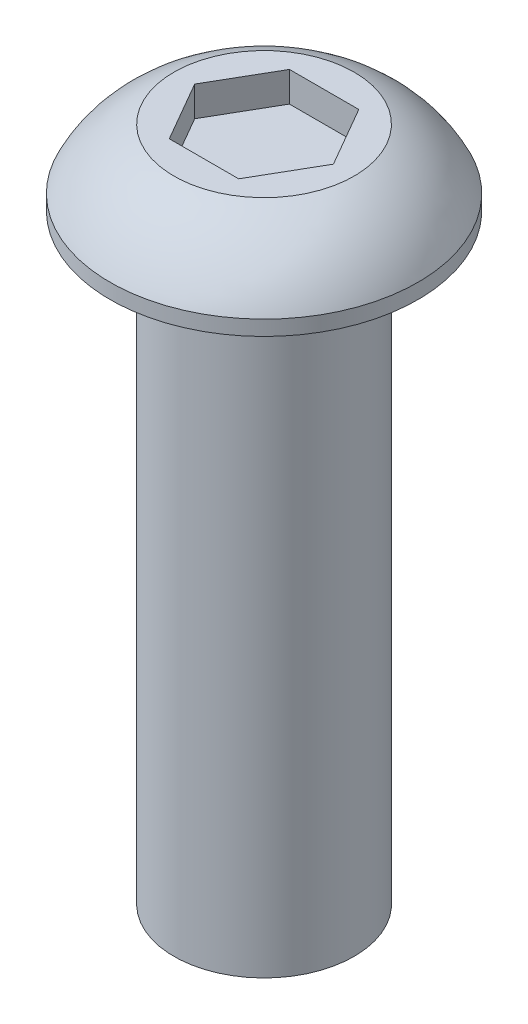
from build123d import *

# Parameters (mm, degrees)
CUT_EXTRUDE1_DEPTH = 1


with BuildPart() as part:
    # Sketch1 → Revolve1 (revolve)
    with BuildSketch(Plane.XY):
        with BuildLine():
            Line((3, 0), (5.125, 0))
            Line((5.125, 0), (5.125, 0.5))
            ThreePointArc((5.125, 0.5), (4.25139218, 1.700697941), (3, 2.5))
            Line((3, 2.5), (0, 2.5))
            Line((0, 2.5), (0, -20))
            Line((0, -20), (3, -20))
            Line((3, -20), (3, 0))
        make_face()
    revolve(axis=Axis((0, -20, 0), (0, 1, 0)))

    # Sketch2 → Cut-Extrude1 (cut)
    with BuildSketch(Plane(origin=(0, 2.5, 0), x_dir=(1, 0, 0), z_dir=(0, 1, 0))):
        Polygon((1.154700538, 2), (-1.154700538, 2), (-2.309401077, 0), (-1.154700538, -2), (1.154700538, -2), (2.309401077, 0), align=None)
    extrude(amount=-CUT_EXTRUDE1_DEPTH, mode=Mode.SUBTRACT)


solid = part.part
